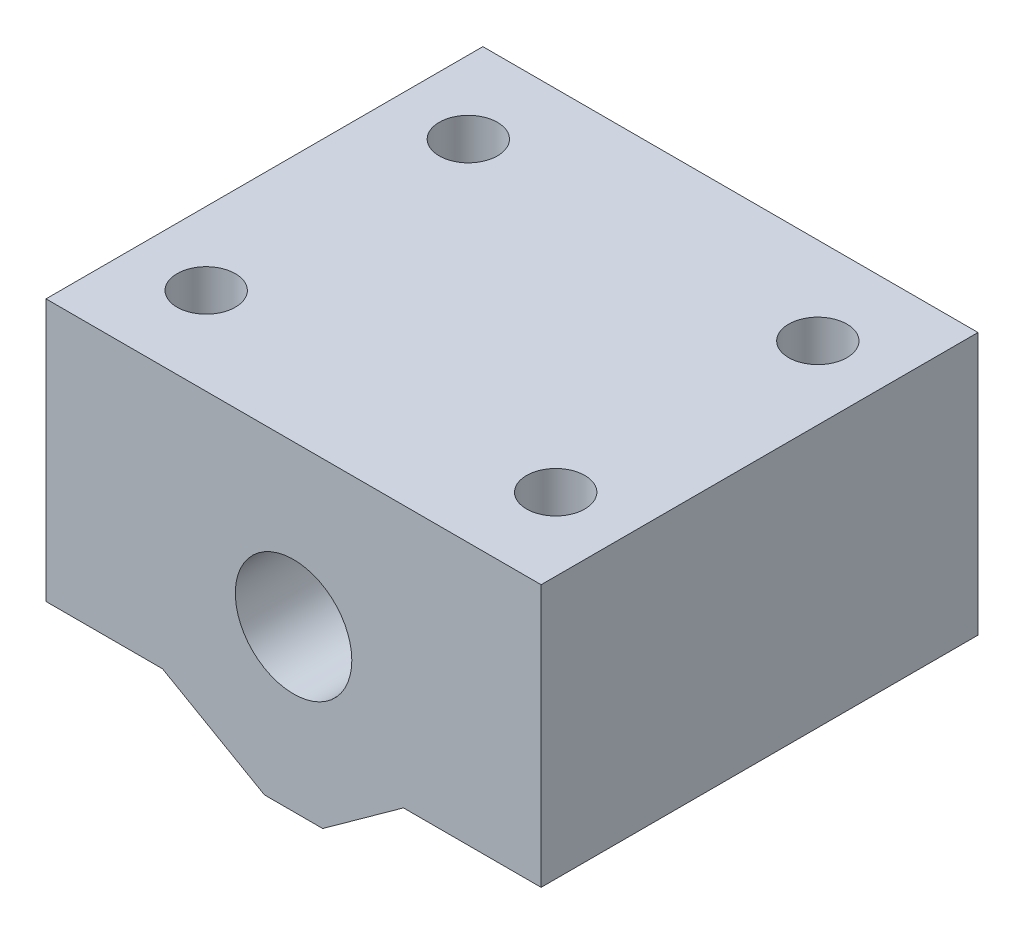
from build123d import *

# Parameters (mm, degrees)
SKETCH2_R           = 4
BOSS_EXTRUDE1_DEPTH = 30
SKETCH4_R           = 2
CUT_EXTRUDE1_DEPTH  = 19


with BuildPart() as part:
    # Sketch2 → Boss-Extrude1 (new body)
    with BuildSketch(Plane.XY):
        Polygon((0, 0), (34, 0), (34, -18), (27.548015077, -18), (24.548015077, -18), (19, -22), (17, -22), (15, -22), (8, -18), (5, -18), (0, -18), align=None)
        with Locations((17, -11)):
            Circle(SKETCH2_R, mode=Mode.SUBTRACT)
    extrude(amount=BOSS_EXTRUDE1_DEPTH)

    # Sketch4 → Cut-Extrude1 (cut, through all)
    with BuildSketch(Plane.XZ.offset(18)):
        with Locations((5, 6)):
            Circle(SKETCH4_R)
        with Locations((29, 6)):
            Circle(SKETCH4_R)
        with Locations((5, 24)):
            Circle(SKETCH4_R)
        with Locations((29, 24)):
            Circle(SKETCH4_R)
    extrude(amount=-CUT_EXTRUDE1_DEPTH, mode=Mode.SUBTRACT)


solid = part.part
